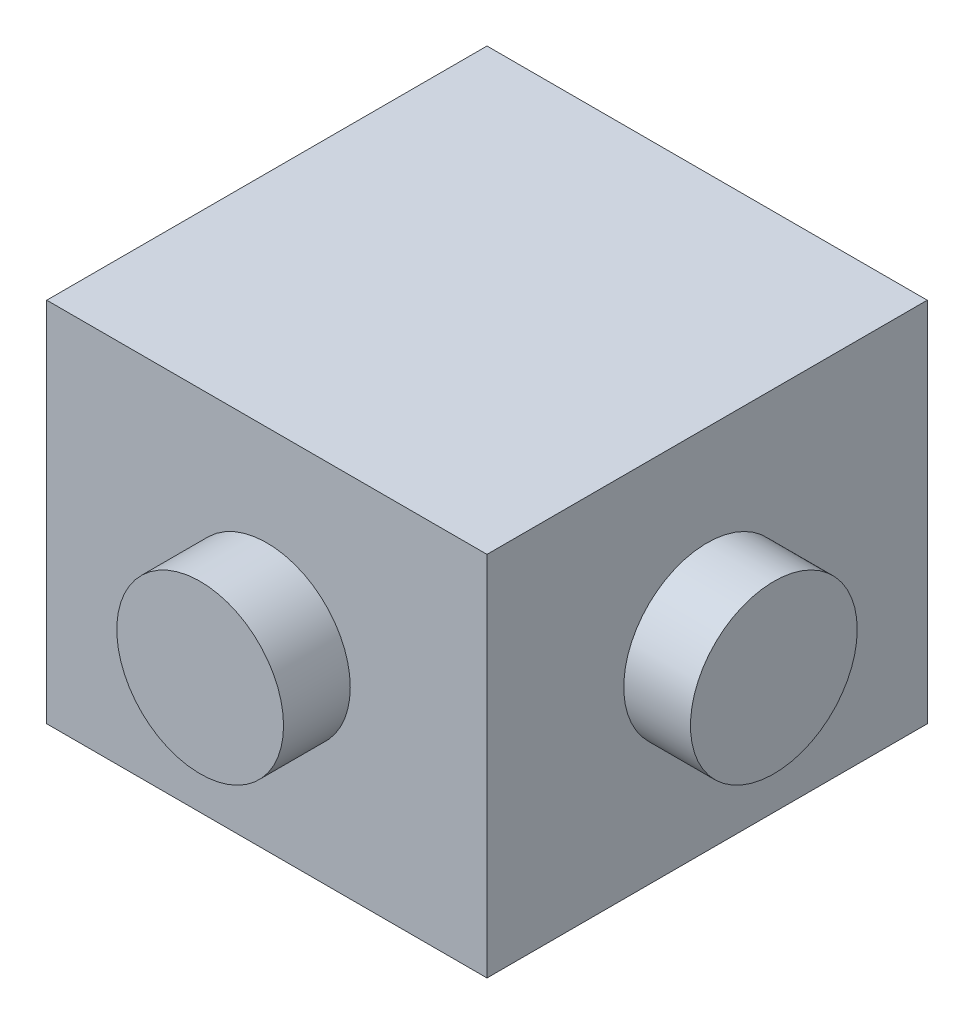
from build123d import *

# Parameters (mm, degrees)
SKETCH1_W           = 16.764
SKETCH1_H           = 16.764
BOSS_EXTRUDE1_DEPTH = 13.97
SKETCH2_R           = 3.175
BOSS_EXTRUDE2_DEPTH = 2.54
SKETCH3_R           = 3.175
BOSS_EXTRUDE3_DEPTH = 2.54


with BuildPart() as part:
    # Sketch1 → Boss-Extrude1 (new body)
    with BuildSketch(Plane(origin=(0, 0, 0), x_dir=(1, 0, 0), z_dir=(0, 1, 0))):
        Rectangle(SKETCH1_W, SKETCH1_H)
    extrude(amount=BOSS_EXTRUDE1_DEPTH)

    # Sketch2 → Boss-Extrude2 (add)
    with BuildSketch(Plane.XY.offset(8.382)):
        with Locations((0, 6.985)):
            Circle(SKETCH2_R)
    boss_extrude2 = extrude(amount=BOSS_EXTRUDE2_DEPTH)

    # Mirror1: Boss-Extrude2 across plane
    add(boss_extrude2.mirror(Plane.XY))

    # Sketch3 → Boss-Extrude3 (add)
    with BuildSketch(Plane(origin=(8.382, 0, 0), x_dir=(0, 0, -1), z_dir=(1, 0, 0))):
        with Locations((0, 6.985)):
            Circle(SKETCH3_R)
    boss_extrude3 = extrude(amount=BOSS_EXTRUDE3_DEPTH)

    # Mirror2: Boss-Extrude3 across plane
    add(boss_extrude3.mirror(Plane(origin=(0, 0, 0), x_dir=(0, 0, 1), z_dir=(1, 0, 0))))


solid = part.part
